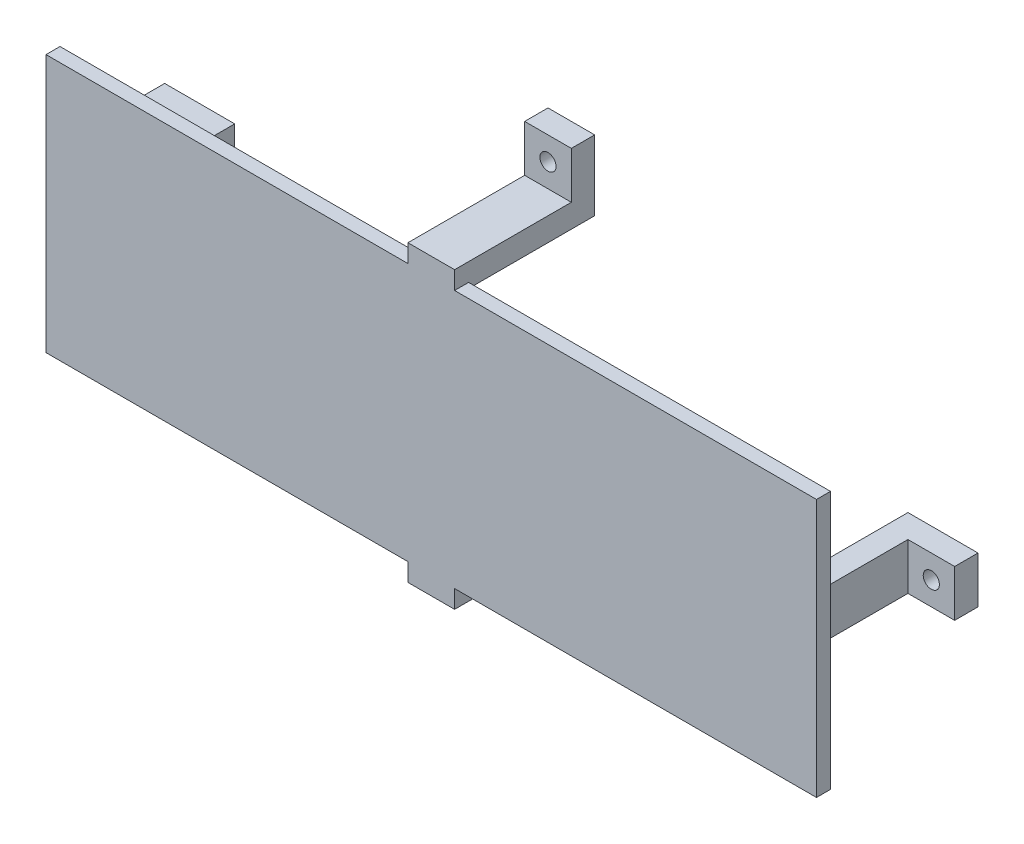
from build123d import *

# Parameters (mm, degrees)
SKETCH2_W             = 5
SKETCH2_H             = 10
BOSS_EXTRUDE1_DEPTH   = 27
SKETCH2_W_2           = 10
SKETCH2_H_2           = 5
BOSS_EXTRUDE1_2_DEPTH = 27
BOSS_EXTRUDE1_3_DEPTH = 27
BOSS_EXTRUDE1_4_DEPTH = 27
SKETCH3_W             = 165
SKETCH3_H             = 55.28
BOSS_EXTRUDE2_DEPTH   = 3
SKETCH4_W             = 10
SKETCH4_H             = 3.86
BOSS_EXTRUDE3_DEPTH   = 3
SKETCH5_W             = 10
SKETCH5_H             = 5
BOSS_EXTRUDE4_DEPTH   = 10
SKETCH7_W             = 5
SKETCH7_H             = 10
BOSS_EXTRUDE5_DEPTH   = 10
SKETCH8_R             = 1.73
CUT_EXTRUDE1_DEPTH    = 6


with BuildPart() as part:
    # Sketch2 → Boss-Extrude1 (new body)
    with BuildSketch(Plane.XY):
        with Locations((-74.585, 0)):
            Rectangle(SKETCH2_W, SKETCH2_H)
    extrude(amount=BOSS_EXTRUDE1_DEPTH)



with BuildPart() as body_2:
    # Sketch2 → Boss-Extrude1 2 (new body)
    with BuildSketch(Plane.XY):
        with Locations((0, 29)):
            Rectangle(SKETCH2_W_2, SKETCH2_H_2)
    extrude(amount=BOSS_EXTRUDE1_2_DEPTH)


with BuildPart() as body_3:
    # Sketch2 → Boss-Extrude1 3 (new body)
    with BuildSketch(Plane.XY):
        with Locations((74.585, 0)):
            Rectangle(SKETCH2_W, SKETCH2_H)
    extrude(amount=BOSS_EXTRUDE1_3_DEPTH)


with BuildPart() as body_4:
    # Sketch2 → Boss-Extrude1 4 (new body)
    with BuildSketch(Plane.XY):
        with Locations((0, -29)):
            Rectangle(SKETCH2_W_2, SKETCH2_H_2)
    extrude(amount=BOSS_EXTRUDE1_4_DEPTH)


with BuildPart() as part_1:
    add(part.part)

    add(body_2.part)  # Boss-Extrude2 merges body 2

    add(body_3.part)  # Boss-Extrude2 merges body 3

    add(body_4.part)  # Boss-Extrude2 merges body 4
    # Sketch3 → Boss-Extrude2 (add)
    with BuildSketch(Plane.XY.offset(27)):
        Rectangle(SKETCH3_W, SKETCH3_H)
    extrude(amount=BOSS_EXTRUDE2_DEPTH)

    # Sketch4 → Boss-Extrude3 (add)
    with BuildSketch(Plane.XY.offset(27)):
        with Locations((0, 29.57)):
            Rectangle(SKETCH4_W, SKETCH4_H)
        with Locations((0, -29.57)):
            Rectangle(SKETCH4_W, SKETCH4_H)
    extrude(amount=BOSS_EXTRUDE3_DEPTH)

    # Sketch5 → Boss-Extrude4 (add)
    with BuildSketch(Plane(origin=(0, 5, 0), x_dir=(1, 0, 0), z_dir=(0, 1, 0))):
        with Locations((-82.085, -2.5)):
            Rectangle(SKETCH5_W, SKETCH5_H)
        with Locations((82.085, -2.5)):
            Rectangle(SKETCH5_W, SKETCH5_H)
    extrude(amount=-BOSS_EXTRUDE4_DEPTH)

    # Sketch7 → Boss-Extrude5 (add)
    with BuildSketch(Plane.ZY.offset(5)):
        with Locations((2.5, 36.5)):
            Rectangle(SKETCH7_W, SKETCH7_H)
        with Locations((2.5, -36.5)):
            Rectangle(SKETCH7_W, SKETCH7_H)
    extrude(amount=-BOSS_EXTRUDE5_DEPTH)

    # Sketch8 → Cut-Extrude1 (cut, through all)
    with BuildSketch(Plane.XY.offset(5)):
        with Locations((-82.085, 0)):
            Circle(SKETCH8_R)
        with Locations((0, -36.5)):
            Circle(SKETCH8_R)
        with Locations((82.085, 0)):
            Circle(SKETCH8_R)
        with Locations((0, 36.5)):
            Circle(SKETCH8_R)
    extrude(amount=-CUT_EXTRUDE1_DEPTH, mode=Mode.SUBTRACT)


solid = part_1.part
